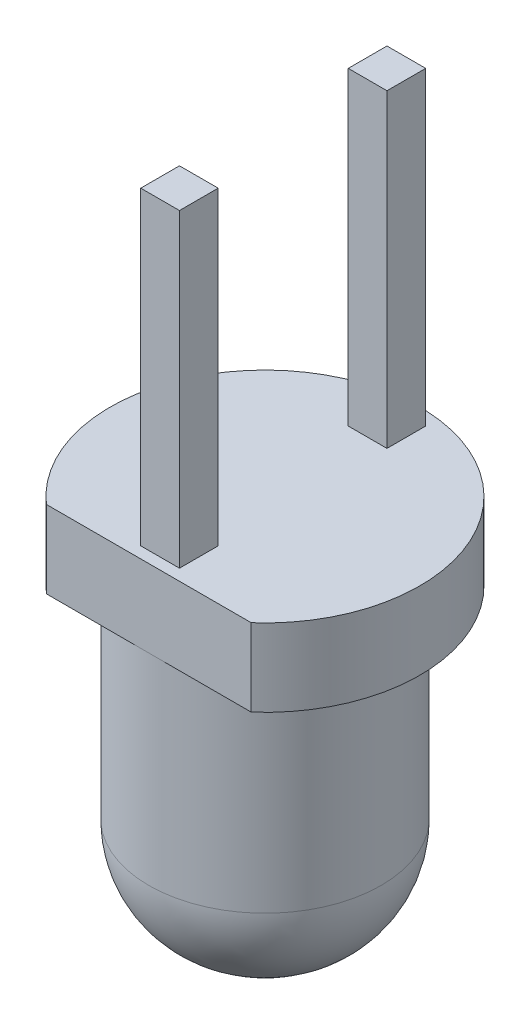
from build123d import *

# Parameters (mm, degrees)
SKETCH_1_R          = 2
EXTRUDE_1_DEPTH     = 1
SKETCH_2_R          = 1.5
EXTRUDE_2_DEPTH     = 4
FILLET_1_R          = 1.4
CUT_EXTRUDE_1_DEPTH = 4
SKETCH_4_W          = 0.5
SKETCH_4_H          = 0.5
EXTRUDE_3_DEPTH     = 4


with BuildPart() as part:
    # Эскиз1 → Бобышка-Вытянуть1 (new body)
    with BuildSketch(Plane(origin=(0, 0, 0), x_dir=(1, 0, 0), z_dir=(0, 1, 0))):
        Circle(SKETCH_1_R)
    extrude(amount=EXTRUDE_1_DEPTH)

    # Эскиз2 → Бобышка-Вытянуть2 (add)
    with BuildSketch(Plane(origin=(0, 0, 0), x_dir=(-1, 0, 0), z_dir=(0, -1, 0))):
        Circle(SKETCH_2_R)
    extrude(amount=EXTRUDE_2_DEPTH)

    # Скругление1
    fillet_1_edges = [part.edges().sort_by_distance(p)[0] for p in [
        (1.5, -4, 0),
    ]]
    fillet(fillet_1_edges, radius=FILLET_1_R)

    # Эскиз3 → Вырез-Вытянуть1 (cut)
    with BuildSketch(Plane.XZ):
        with BuildLine():
            Line((-1.322875656, 1.5), (1.322875656, 1.5))
            ThreePointArc((1.322875656, 1.5), (0, 2), (-1.322875656, 1.5))
        make_face()
    extrude(amount=-CUT_EXTRUDE_1_DEPTH, mode=Mode.SUBTRACT)

    # Эскиз4 → Бобышка-Вытянуть3 (add)
    with BuildSketch(Plane(origin=(0, 1, 0), x_dir=(1, 0, 0), z_dir=(0, 1, 0))):
        with Locations((0, -1.103924033)):
            Rectangle(SKETCH_4_W, SKETCH_4_H)
        with Locations((0, 1.575495182)):
            Rectangle(SKETCH_4_W, SKETCH_4_H)
    extrude(amount=EXTRUDE_3_DEPTH)


solid = part.part
